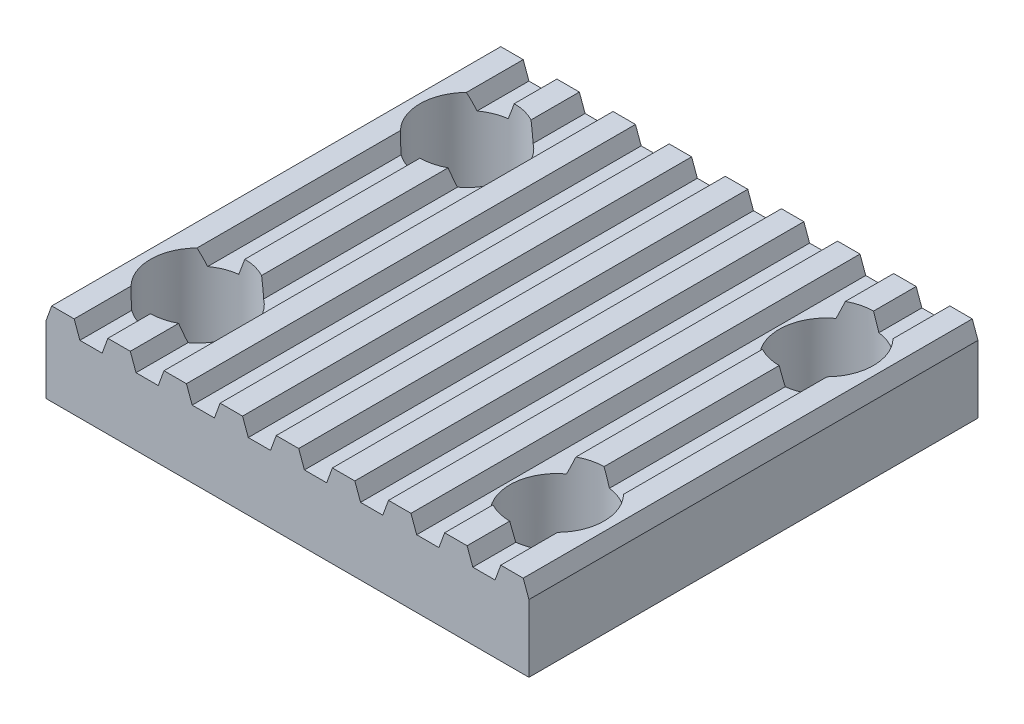
from build123d import *

# Parameters (mm, degrees)
BOSS_EXTRUDE1_DEPTH = 10
SKETCH2_R           = 2.1
CUT_EXTRUDE1_DEPTH  = 4.7


with BuildPart() as part:
    # Sketch1 → Boss-Extrude1 (new body, symmetric)
    with BuildSketch(Plane.XY):
        Polygon((-10.754779164, 1.5), (-10.5, 2.2), (-9.5, 2.2), (-9.245220836, 1.5), (-8.254779164, 1.5), (-8, 2.2), (-7, 2.2), (-6.745220836, 1.5), (-5.754779164, 1.5), (-5.5, 2.2), (-4.5, 2.2), (-4.245220836, 1.5), (-3.254779164, 1.5), (-3, 2.2), (-2, 2.2), (-1.745220836, 1.5), (-0.754779164, 1.5), (-0.5, 2.2), (0.5, 2.2), (0.754779164, 1.5), (1.745220836, 1.5), (2, 2.2), (3, 2.2), (3.254779164, 1.5), (4.245220836, 1.5), (4.5, 2.2), (5.5, 2.2), (5.754779164, 1.5), (6.745220836, 1.5), (7, 2.2), (8, 2.2), (8.254779164, 1.5), (9.245220836, 1.5), (9.5, 2.2), (10.5, 2.2), (10.754779164, 1.5), (10.754779164, -1.5), (-10.754779164, -1.5), align=None)
    extrude(amount=BOSS_EXTRUDE1_DEPTH, both=True)

    # Sketch2 → Cut-Extrude1 (cut, through all)
    with BuildSketch(Plane.XZ.offset(1.5)):
        with Locations((-8, -6)):
            Circle(SKETCH2_R)
        with Locations((8, -6)):
            Circle(SKETCH2_R)
        with Locations((8, 6)):
            Circle(SKETCH2_R)
        with Locations((-8, 6)):
            Circle(SKETCH2_R)
    extrude(amount=-CUT_EXTRUDE1_DEPTH, mode=Mode.SUBTRACT)


solid = part.part
